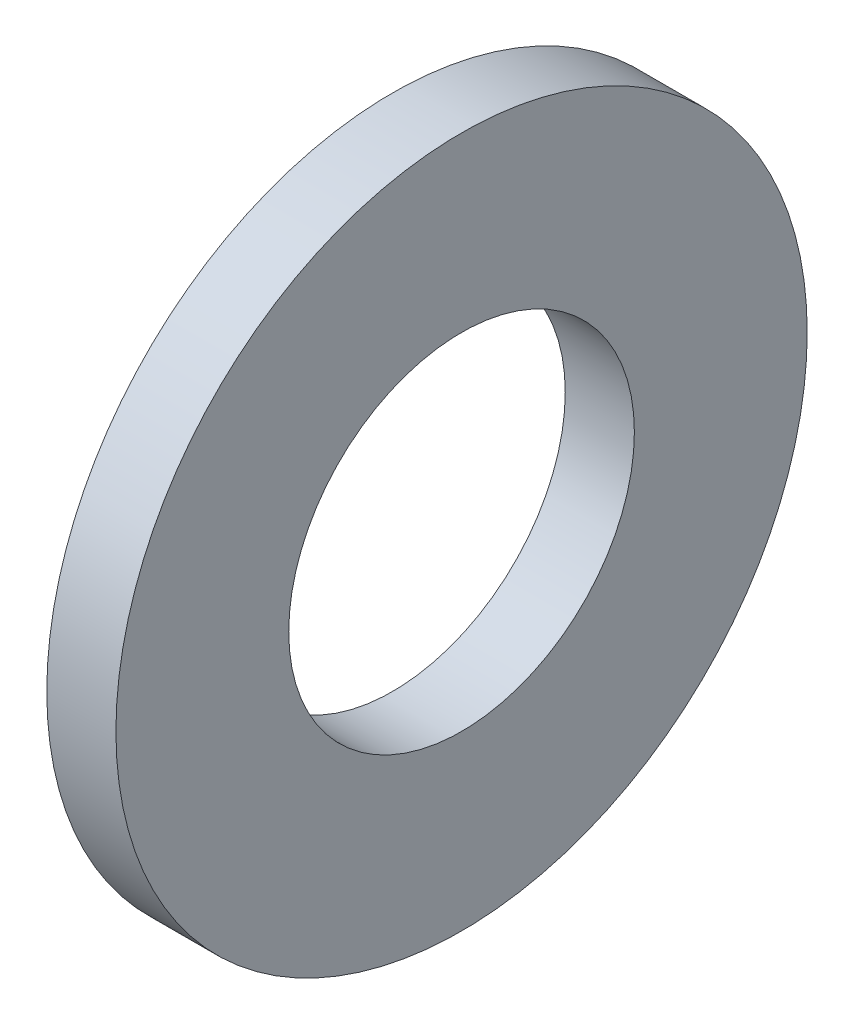
from build123d import *

# Parameters (mm, degrees)
SKETCH1_W = 1
SKETCH1_H = 2.5


with BuildPart() as part:
    # Sketch1 → Revolve1 (revolve)
    with BuildSketch(Plane.XY):
        with Locations((0.5, 3.75)):
            Rectangle(SKETCH1_W, SKETCH1_H)
    revolve(axis=Axis((-0.05, 0, 0), (1, 0, 0)))


solid = part.part
